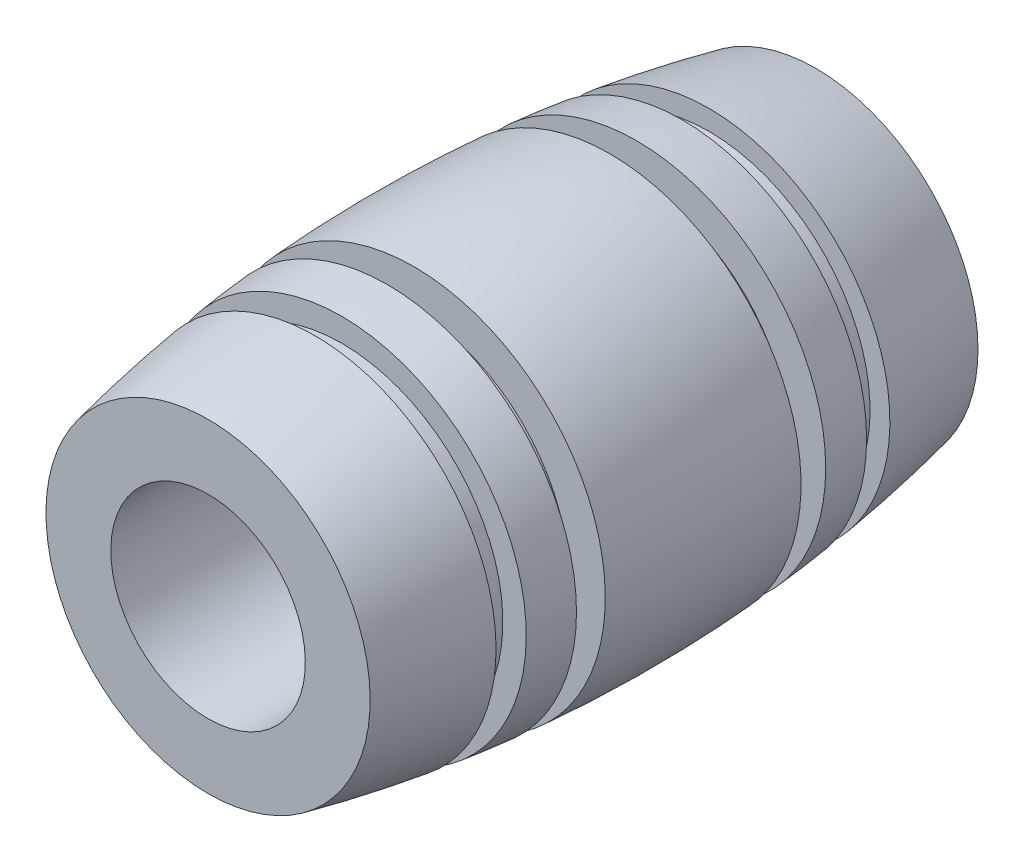
from build123d import *

# Parameters (mm, degrees)
SKETCH4_W   = 1.1
SKETCH4_H   = 1.375
SKETCH4_H_2 = 1.65


with BuildPart() as part:
    # Sketch5 → Revolve1 (revolve)
    with BuildSketch(Plane(origin=(0, 0, 0), x_dir=(0, 0, -1), z_dir=(1, 0, 0))):
        with BuildLine():
            Line((-12.5, 4), (12.5, 4))
            Line((12.5, 4), (12.5, 6.666666667))
            ThreePointArc((12.5, 6.666666667), (0, 8), (-12.5, 6.666666667))
            Line((-12.5, 6.666666667), (-12.5, 4))
        make_face()
    revolve(axis=Axis((0, 0, 12.5), (0, 0, -1)))

    # Sketch4 → Cut-Revolve1 (revolve, cut)
    with BuildSketch(Plane(origin=(0, 0, 0), x_dir=(0, 0, -1), z_dir=(1, 0, 0))):
        with Locations((-7.55, -7.3125)):
            Rectangle(SKETCH4_W, SKETCH4_H)
        with Locations((7.55, -7.3125)):
            Rectangle(SKETCH4_W, SKETCH4_H)
        with Locations((-4.575, -7.175)):
            Rectangle(SKETCH4_W, SKETCH4_H_2)
        with Locations((4.575, -7.175)):
            Rectangle(SKETCH4_W, SKETCH4_H_2)
    revolve(axis=Axis((0, 0, 12.5), (0, 0, -1)), mode=Mode.SUBTRACT)


solid = part.part
